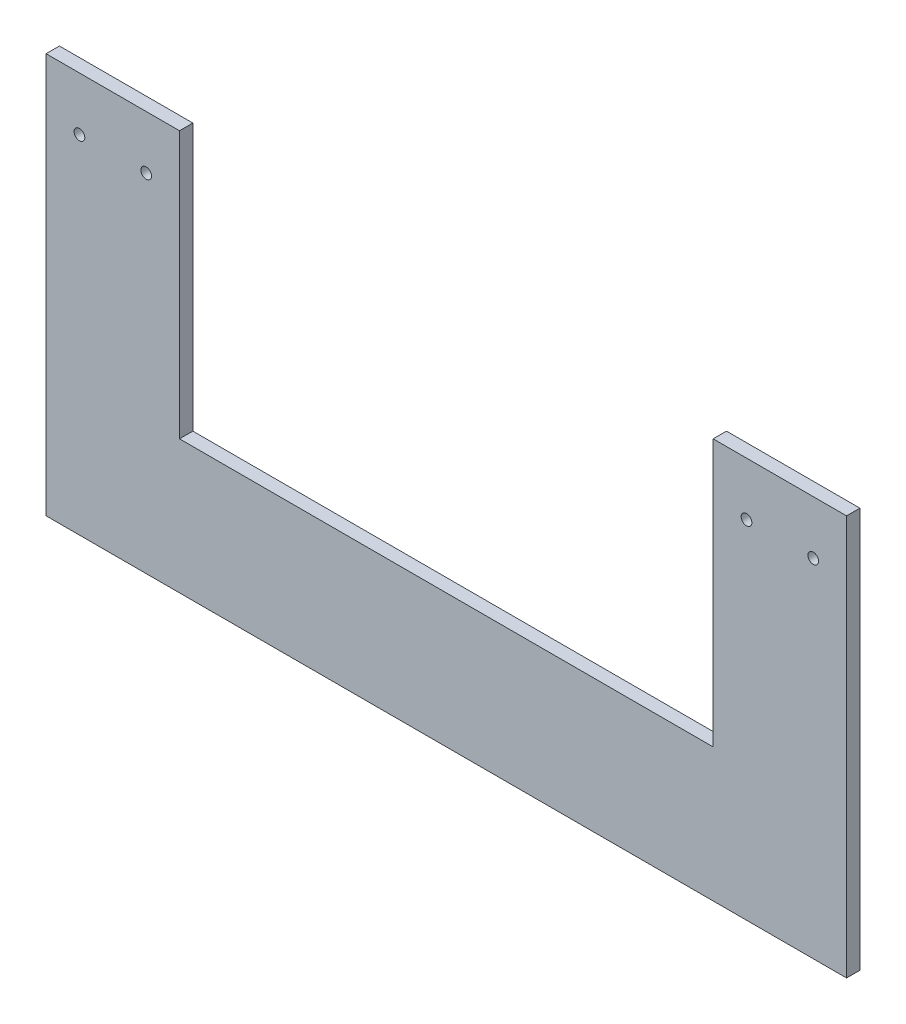
from build123d import *

# Parameters (mm, degrees)
SKETCH2_R           = 2
BOSS_EXTRUDE1_DEPTH = 5


with BuildPart() as part:
    # Sketch2 → Boss-Extrude1 (new body)
    with BuildSketch(Plane.XY):
        Polygon((-54.712711464, 96.249572406), (-4.712711464, 96.249572406), (-4.712711464, -3.750427594), (195.287288536, -3.750427594), (195.287288536, 96.249572406), (245.287288536, 96.249572406), (245.287288536, -53.750427594), (-54.712711464, -53.750427594), align=None)
        with Locations((-42.212711464, 76.249572406)):
            Circle(SKETCH2_R, mode=Mode.SUBTRACT)
        with Locations((232.787288536, 76.249572406)):
            Circle(SKETCH2_R, mode=Mode.SUBTRACT)
        with Locations((207.787288536, 76.249572406)):
            Circle(SKETCH2_R, mode=Mode.SUBTRACT)
        with Locations((-17.212711464, 76.249572406)):
            Circle(SKETCH2_R, mode=Mode.SUBTRACT)
    extrude(amount=BOSS_EXTRUDE1_DEPTH)


solid = part.part
